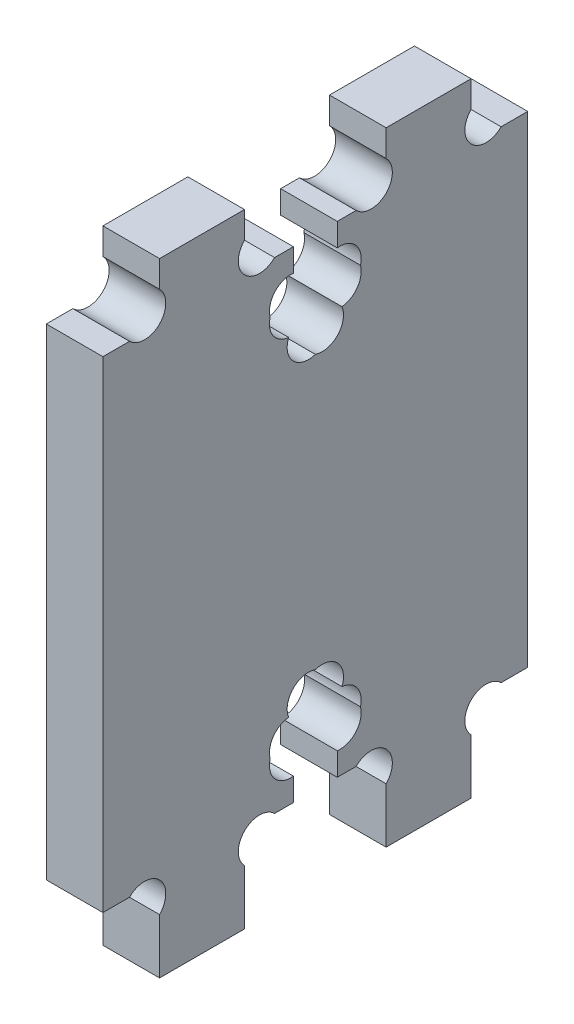
from build123d import *

# Parameters (mm, degrees)
CROQUIS1_W              = 34
CROQUIS1_H              = 30
SALIENTE_EXTRUIR1_DEPTH = 4
CROQUIS2_W              = 6
CROQUIS2_H              = 4
SALIENTE_EXTRUIR2_DEPTH = 4
CORTAR_EXTRUIR1_DEPTH   = 5
CROQUIS4_W              = 6
CROQUIS4_H              = 2
SALIENTE_EXTRUIR3_DEPTH = 4
CROQUIS5_R              = 1.5
CORTAR_EXTRUIR2_DEPTH   = 5
CORTAR_EXTRUIR4_DEPTH   = 5
CORTAR_EXTRUIR6_DEPTH   = 5


with BuildPart() as part:
    # Croquis1 → Saliente-Extruir1 (new body)
    with BuildSketch(Plane(origin=(0, 0, 0), x_dir=(0, -1, 0), z_dir=(1, 0, 0))):
        Rectangle(CROQUIS1_W, CROQUIS1_H)
    extrude(amount=SALIENTE_EXTRUIR1_DEPTH)

    # Croquis2 → Saliente-Extruir2 (add, through all)
    with BuildSketch(Plane(origin=(4, 0, 0), x_dir=(0, 0, -1), z_dir=(1, 0, 0))):
        with Locations((-8, -19)):
            Rectangle(CROQUIS2_W, CROQUIS2_H)
        with Locations((8, -19)):
            Rectangle(CROQUIS2_W, CROQUIS2_H)
        with Locations((8, 19)):
            Rectangle(CROQUIS2_W, CROQUIS2_H)
        with Locations((-8, 19)):
            Rectangle(CROQUIS2_W, CROQUIS2_H)
    extrude(amount=-SALIENTE_EXTRUIR2_DEPTH)

    # Croquis3 → Cortar-Extruir1 (cut, through all)
    with BuildSketch(Plane(origin=(4, 0, 0), x_dir=(0, 0, -1), z_dir=(1, 0, 0))):
        Polygon((-1.55, 17), (-1.55, 14.95), (-2.8, 14.95), (-2.8, 12.05), (-1.55, 12.05), (-1.55, 10), (1.55, 10), (1.55, 12.05), (2.8, 12.05), (2.8, 14.95), (1.55, 14.95), (1.55, 17), align=None)
        Polygon((1.55, -12.05), (2.8, -12.05), (2.8, -14.95), (1.55, -14.95), (1.55, -17), (-1.55, -17), (-1.55, -14.95), (-2.8, -14.95), (-2.8, -12.05), (-1.55, -12.05), (-1.55, -10), (1.55, -10), align=None)
    extrude(amount=-CORTAR_EXTRUIR1_DEPTH, mode=Mode.SUBTRACT)

    # Croquis4 → Saliente-Extruir3 (add, through all)
    with BuildSketch(Plane(origin=(4, 0, 0), x_dir=(0, 0, -1), z_dir=(1, 0, 0))):
        with Locations((-8, -22)):
            Rectangle(CROQUIS4_W, CROQUIS4_H)
        with Locations((8, -22)):
            Rectangle(CROQUIS4_W, CROQUIS4_H)
    extrude(amount=-SALIENTE_EXTRUIR3_DEPTH)

    # Croquis5 → Cortar-Extruir2 (cut, through all)
    with BuildSketch(Plane(origin=(4, 0, 0), x_dir=(0, 0, -1), z_dir=(1, 0, 0))):
        with Locations((-12.060660172, -18.060660172)):
            Circle(CROQUIS5_R)
        with Locations((-3.939339828, -18.060660172)):
            Circle(CROQUIS5_R)
        with Locations((12.060660172, -18.060660172)):
            Circle(CROQUIS5_R)
        with Locations((3.939339828, -18.060660172)):
            Circle(CROQUIS5_R)
        with Locations((-12.060660172, 18.060660172)):
            Circle(CROQUIS5_R)
        with Locations((-3.939339828, 18.060660172)):
            Circle(CROQUIS5_R)
        with Locations((3.939339828, 18.060660172)):
            Circle(CROQUIS5_R)
        with Locations((12.060660172, 18.060660172)):
            Circle(CROQUIS5_R)
    extrude(amount=-CORTAR_EXTRUIR2_DEPTH, mode=Mode.SUBTRACT)

    # Croquis6 → Cortar-Extruir4 (cut, through all)
    with BuildSketch(Plane(origin=(4, 0, 0), x_dir=(0, 0, -1), z_dir=(1, 0, 0))):
        with BuildLine():
            ThreePointArc((0, -9.64272275), (-1.989339828, -11.060660172), (0, -12.478597594))
            ThreePointArc((0, -12.478597594), (1.989339828, -11.060660172), (0, -9.64272275))
        make_face()
        with BuildLine():
            ThreePointArc((0, 9.64272275), (-1.989339828, 11.060660172), (0, 12.478597594))
            ThreePointArc((0, 12.478597594), (1.989339828, 11.060660172), (0, 9.64272275))
        make_face()
    extrude(amount=-CORTAR_EXTRUIR4_DEPTH, mode=Mode.SUBTRACT)

    # Croquis7 → Cortar-Extruir6 (cut, through all)
    with BuildSketch(Plane(origin=(4, 0, 0), x_dir=(0, 0, -1), z_dir=(1, 0, 0))):
        with BuildLine():
            ThreePointArc((-0.290749307, -13.5), (-1.739339828, -11.610660172), (-3.187930349, -13.5))
            ThreePointArc((-3.187930349, -13.5), (-1.739339828, -15.389339828), (-0.290749307, -13.5))
        make_face()
        with BuildLine():
            ThreePointArc((0.290749307, -13.5), (1.739339828, -11.610660172), (3.187930349, -13.5))
            ThreePointArc((3.187930349, -13.5), (1.739339828, -15.389339828), (0.290749307, -13.5))
        make_face()
        with BuildLine():
            ThreePointArc((0.290749307, 13.5), (1.739339828, 11.610660172), (3.187930349, 13.5))
            ThreePointArc((3.187930349, 13.5), (1.739339828, 15.389339828), (0.290749307, 13.5))
        make_face()
        with BuildLine():
            ThreePointArc((-0.290749307, 13.5), (-1.739339828, 15.389339828), (-3.187930349, 13.5))
            ThreePointArc((-3.187930349, 13.5), (-1.739339828, 11.610660172), (-0.290749307, 13.5))
        make_face()
    extrude(amount=-CORTAR_EXTRUIR6_DEPTH, mode=Mode.SUBTRACT)


solid = part.part
